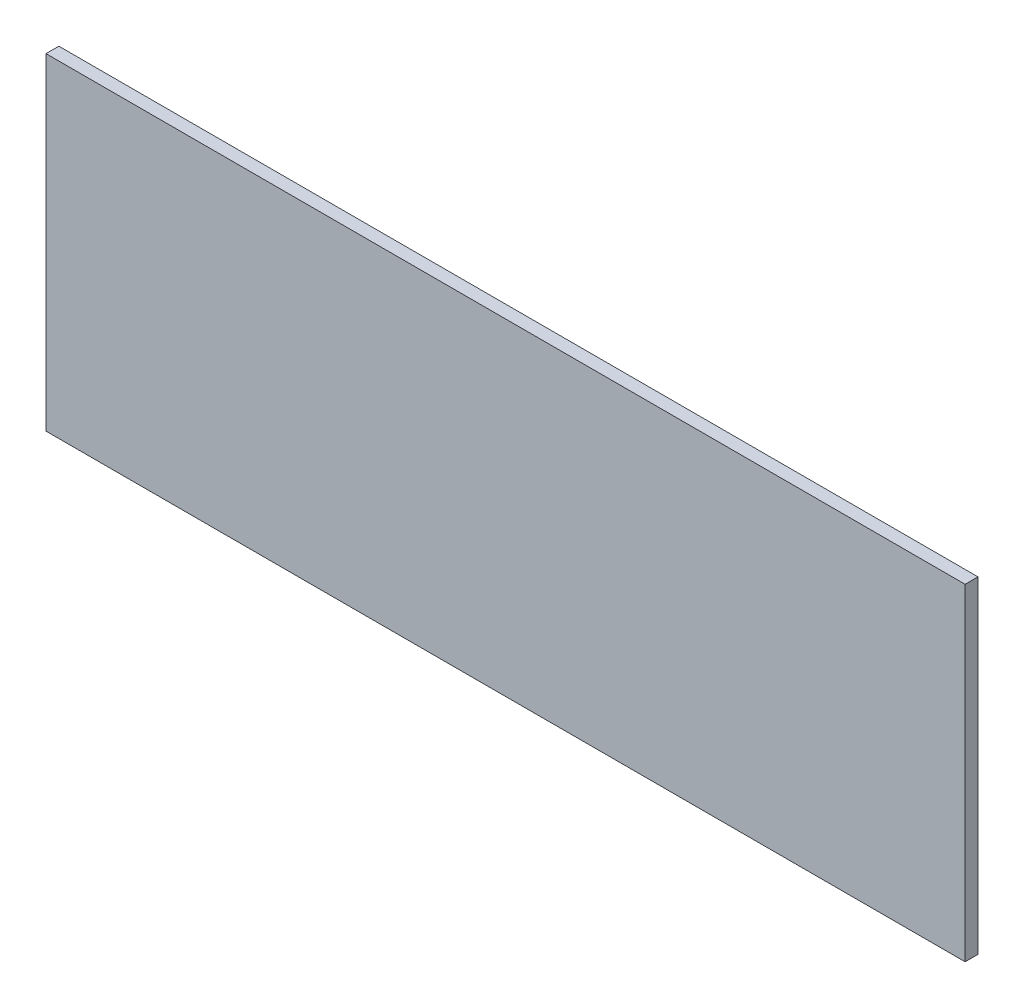
from build123d import *

# Parameters (mm, degrees)
SKETCH1_W           = 214.216
SKETCH1_H           = 76.2
BOSS_EXTRUDE1_DEPTH = 1.5


with BuildPart() as part:
    # Sketch1 → Boss-Extrude1 (new body, symmetric)
    with BuildSketch(Plane.XY):
        with Locations((107.108, 38.1)):
            Rectangle(SKETCH1_W, SKETCH1_H)
    extrude(amount=BOSS_EXTRUDE1_DEPTH, both=True)


solid = part.part
